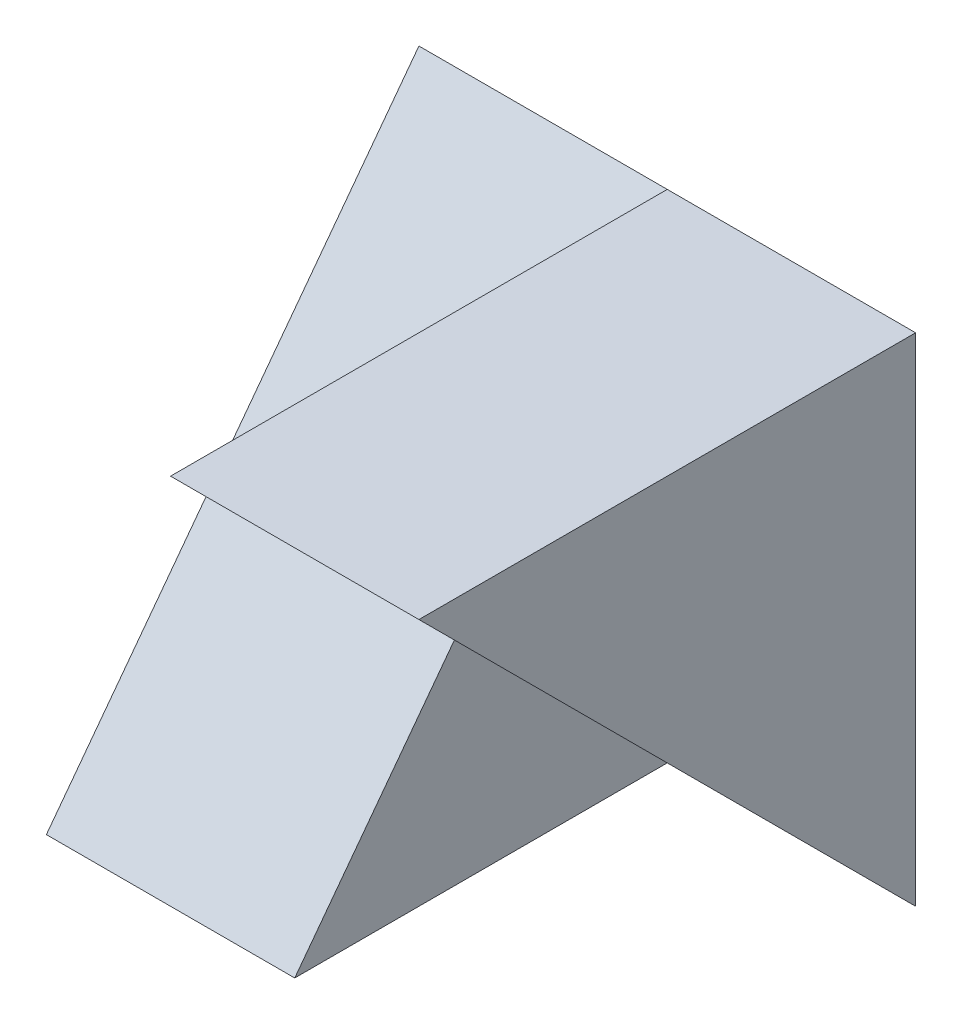
from build123d import *

# Parameters (mm, degrees)
SKETCH1_W           = 4
SKETCH1_H           = 4
BOSS_EXTRUDE1_DEPTH = 2
SKETCH2_W           = 3
SKETCH2_H           = 4
BOSS_EXTRUDE2_DEPTH = 2
CUT_EXTRUDE1_DEPTH  = 2
CUT_EXTRUDE2_DEPTH  = 2


with BuildPart() as part:
    # Sketch1 → Boss-Extrude1 (new body)
    with BuildSketch(Plane(origin=(0, 0, 0), x_dir=(0, 0, -1), z_dir=(1, 0, 0))):
        with Locations((2, 2)):
            Rectangle(SKETCH1_W, SKETCH1_H)
    extrude(amount=BOSS_EXTRUDE1_DEPTH)

    # Sketch2 → Boss-Extrude2 (add)
    with BuildSketch(Plane.ZY):
        with Locations((-2.5, 2)):
            Rectangle(SKETCH2_W, SKETCH2_H)
    extrude(amount=BOSS_EXTRUDE2_DEPTH)

    # Sketch3 → Cut-Extrude1 (cut)
    with BuildSketch(Plane(origin=(2, 0, 0), x_dir=(0, 0, -1), z_dir=(1, 0, 0))):
        Polygon((4, 0), (0, 4), (0, 0), align=None)
    extrude(amount=-CUT_EXTRUDE1_DEPTH, mode=Mode.SUBTRACT)

    # Sketch4 → Cut-Extrude2 (cut)
    with BuildSketch(Plane.ZY.offset(2)):
        Polygon((-1, 0), (-4, 4), (-1, 4), align=None)
    extrude(amount=-CUT_EXTRUDE2_DEPTH, mode=Mode.SUBTRACT)


solid = part.part
